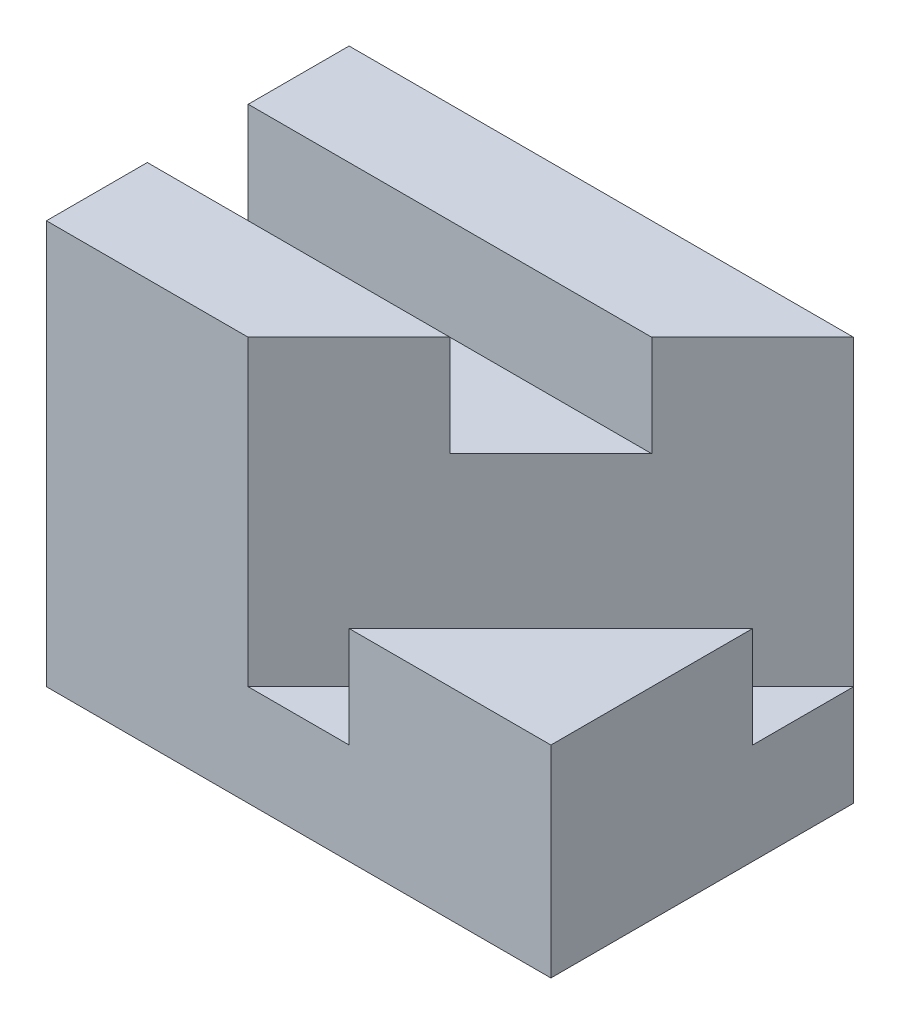
from build123d import *

# Parameters (mm, degrees)
BOSS_EXTRUDE1_DEPTH = 10
BOSS_EXTRUDE2_DEPTH = 20
BOSS_EXTRUDE3_DEPTH = 30
BOSS_EXTRUDE4_DEPTH = 40


with BuildPart() as part:
    # Sketch1 → Boss-Extrude1 (new body)
    with BuildSketch(Plane(origin=(0, 0, 0), x_dir=(1, 0, 0), z_dir=(0, 1, 0))):
        Polygon((30, 10), (20, 0), (30, 0), (50, 20), (50, 30), (40, 20), align=None)
    extrude(amount=BOSS_EXTRUDE1_DEPTH)

    # Sketch1_3 → Boss-Extrude2 (add)
    with BuildSketch(Plane(origin=(0, 0, 0), x_dir=(1, 0, 0), z_dir=(0, 1, 0))):
        Polygon((50, 20), (30, 0), (50, 0), align=None)
    extrude(amount=BOSS_EXTRUDE2_DEPTH)

    # Sketch1_4 → Boss-Extrude3 (add)
    with BuildSketch(Plane(origin=(0, 0, 0), x_dir=(1, 0, 0), z_dir=(0, 1, 0))):
        Polygon((0, 20), (0, 10), (30, 10), (40, 20), align=None)
    extrude(amount=BOSS_EXTRUDE3_DEPTH)

    # Sketch1_5 → Boss-Extrude4 (add)
    with BuildSketch(Plane(origin=(0, 0, 0), x_dir=(1, 0, 0), z_dir=(0, 1, 0))):
        Polygon((0, 10), (0, 0), (20, 0), (30, 10), align=None)
        Polygon((0, 30), (0, 20), (40, 20), (50, 30), align=None)
    extrude(amount=BOSS_EXTRUDE4_DEPTH)


solid = part.part
